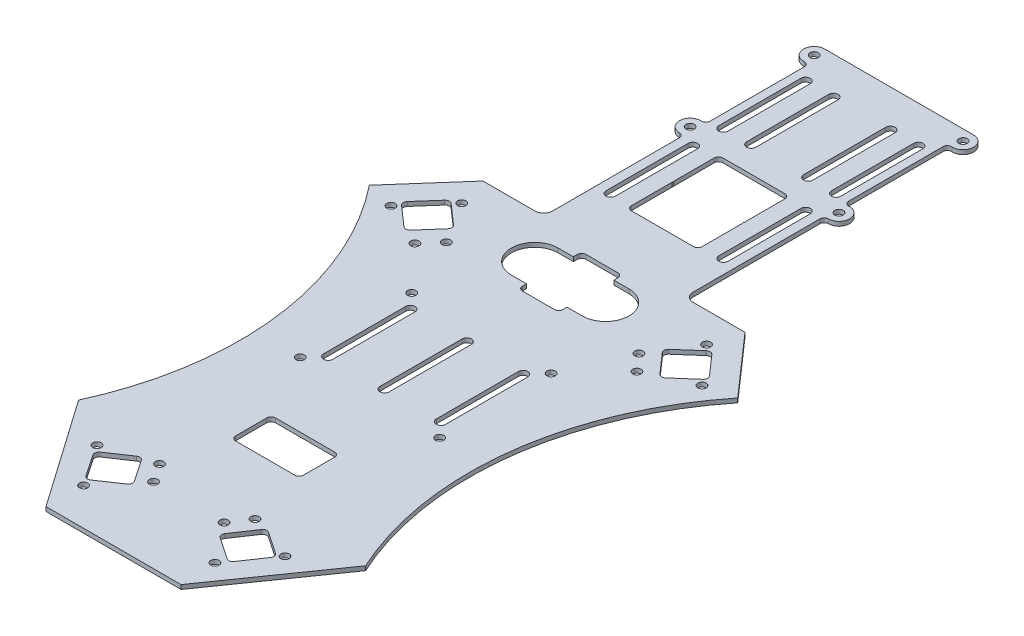
from build123d import *

# Parameters (mm, degrees)
BOSS_EXTRUDE1_DEPTH = 1.53
SKETCH2_R           = 1.5
CUT_EXTRUDE1_DEPTH  = 1.53


with BuildPart() as part:
    # Sketch1 → Boss-Extrude1 (new body)
    with BuildSketch(Plane(origin=(0, 0, 0), x_dir=(1, 0, 0), z_dir=(0, 1, 0))):
        with BuildLine():
            Line((-24.225, -100.313959073), (24.225, -100.313959073))
            Line((24.225, -100.313959073), (51.475, -61.381343132))
            ThreePointArc((51.475, -61.381343132), (41.92219647, 0.128398889), (66.075, 57.498656868))
            Line((66.075, 57.498656868), (47, 79.196040927))
            Line((47, 79.196040927), (28.38, 79.196040927))
            ThreePointArc((28.38, 79.196040927), (26.131400436, 80.127441362), (25.2, 82.376040927))
            Line((25.2, 82.376040927), (25.2, 127.896040927))
            ThreePointArc((25.2, 127.896040927), (25.639339828, 128.956701098), (26.7, 129.396040927))
            ThreePointArc((26.7, 129.396040927), (30.497925704, 133.321581153), (26.449056604, 136.987746006))
            ThreePointArc((26.449056604, 136.987746006), (25.324959734, 137.389349578), (24.85, 138.484471696))
            Line((24.85, 138.484471696), (24.85, 172.407610157))
            ThreePointArc((24.85, 172.407610157), (25.324959734, 173.502732275), (26.449056604, 173.904335847))
            ThreePointArc((26.449056604, 173.904335847), (30.497925704, 177.5705007), (26.7, 181.496040927))
            Line((26.7, 181.496040927), (-26.7, 181.496040927))
            ThreePointArc((-26.7, 181.496040927), (-30.497925704, 177.5705007), (-26.449056604, 173.904335847))
            ThreePointArc((-26.449056604, 173.904335847), (-25.324959734, 173.502732275), (-24.85, 172.407610157))
            Line((-24.85, 172.407610157), (-24.85, 138.484471696))
            ThreePointArc((-24.85, 138.484471696), (-25.324959734, 137.389349578), (-26.449056604, 136.987746006))
            ThreePointArc((-26.449056604, 136.987746006), (-30.497925704, 133.321581153), (-26.7, 129.396040927))
            ThreePointArc((-26.7, 129.396040927), (-25.639339828, 128.956701098), (-25.2, 127.896040927))
            Line((-25.2, 127.896040927), (-25.2, 82.376040927))
            ThreePointArc((-25.2, 82.376040927), (-26.131400436, 80.127441362), (-28.38, 79.196040927))
            Line((-28.38, 79.196040927), (-47, 79.196040927))
            Line((-47, 79.196040927), (-66.075, 57.498656868))
            ThreePointArc((-66.075, 57.498656868), (-41.92219647, 0.128398889), (-51.475, -61.381343132))
            Line((-51.475, -61.381343132), (-24.225, -100.313959073))
        make_face()
        with BuildLine():
            Line((-26.611630339, -83.593554115), (-31.856126021, -75.840821368))
            ThreePointArc((-31.856126021, -75.840821368), (-32.097277956, -74.663642225), (-31.43540677, -73.660730702))
            Line((-31.43540677, -73.660730702), (-23.682674023, -68.41623502))
            ThreePointArc((-23.682674023, -68.41623502), (-22.50549488, -68.175083085), (-21.502583357, -68.836954272))
            Line((-21.502583357, -68.836954272), (-16.258087675, -76.589687018))
            ThreePointArc((-16.258087675, -76.589687018), (-16.016935741, -77.766866161), (-16.678806927, -78.769777684))
            Line((-16.678806927, -78.769777684), (-24.431539674, -84.014273366))
            ThreePointArc((-24.431539674, -84.014273366), (-25.608718816, -84.255425301), (-26.611630339, -83.593554115))
        make_face(mode=Mode.SUBTRACT)
        with BuildLine():
            ThreePointArc((-21.9, 26.376040927), (-20.22, 28.056040927), (-18.54, 26.376040927))
            Line((-18.54, 26.376040927), (-18.54, -3.083959073))
            ThreePointArc((-18.54, -3.083959073), (-20.22, -4.763959073), (-21.9, -3.083959073))
            Line((-21.9, -3.083959073), (-21.9, 26.376040927))
        make_face(mode=Mode.SUBTRACT)
        with BuildLine():
            ThreePointArc((26.611630339, -83.593554115), (25.608718816, -84.255425301), (24.431539674, -84.014273366))
            Line((24.431539674, -84.014273366), (16.678806927, -78.769777684))
            ThreePointArc((16.678806927, -78.769777684), (16.016935741, -77.766866161), (16.258087675, -76.589687018))
            Line((16.258087675, -76.589687018), (21.502583357, -68.836954272))
            ThreePointArc((21.502583357, -68.836954272), (22.50549488, -68.175083085), (23.682674023, -68.41623502))
            Line((23.682674023, -68.41623502), (31.43540677, -73.660730702))
            ThreePointArc((31.43540677, -73.660730702), (32.097277956, -74.663642225), (31.856126021, -75.840821368))
            Line((31.856126021, -75.840821368), (26.611630339, -83.593554115))
        make_face(mode=Mode.SUBTRACT)
        with BuildLine():
            Line((-10.615, -31.603959073), (10.615, -31.603959073))
            ThreePointArc((10.615, -31.603959073), (11.725157646, -32.063801427), (12.185, -33.173959073))
            Line((12.185, -33.173959073), (12.185, -44.353959073))
            ThreePointArc((12.185, -44.353959073), (11.725157646, -45.46411672), (10.615, -45.923959073))
            Line((10.615, -45.923959073), (-10.615, -45.923959073))
            ThreePointArc((-10.615, -45.923959073), (-11.725157646, -45.46411672), (-12.185, -44.353959073))
            Line((-12.185, -44.353959073), (-12.185, -33.173959073))
            ThreePointArc((-12.185, -33.173959073), (-11.725157646, -32.063801427), (-10.615, -31.603959073))
        make_face(mode=Mode.SUBTRACT)
        with BuildLine():
            ThreePointArc((-1.68, 26.376040927), (0, 28.056040927), (1.68, 26.376040927))
            Line((1.68, 26.376040927), (1.68, -3.083959073))
            ThreePointArc((1.68, -3.083959073), (0, -4.763959073), (-1.68, -3.083959073))
            Line((-1.68, -3.083959073), (-1.68, 26.376040927))
        make_face(mode=Mode.SUBTRACT)
        with BuildLine():
            Line((18.54, -3.083959073), (18.54, 26.376040927))
            ThreePointArc((18.54, 26.376040927), (20.22, 28.056040927), (21.9, 26.376040927))
            Line((21.9, 26.376040927), (21.9, -3.083959073))
            ThreePointArc((21.9, -3.083959073), (20.22, -4.763959073), (18.54, -3.083959073))
        make_face(mode=Mode.SUBTRACT)
        with BuildLine():
            ThreePointArc((-54.040190621, 57.042105422), (-54.570340289, 58.120458945), (-54.182701627, 59.257842459))
            Line((-54.182701627, 59.257842459), (-47.936613015, 66.362627962))
            ThreePointArc((-47.936613015, 66.362627962), (-46.858259493, 66.892777631), (-45.720875979, 66.505138968))
            Line((-45.720875979, 66.505138968), (-38.616090475, 60.259050356))
            ThreePointArc((-38.616090475, 60.259050356), (-38.085940807, 59.180696834), (-38.473579469, 58.04331332))
            Line((-38.473579469, 58.04331332), (-44.719668081, 50.938527817))
            ThreePointArc((-44.719668081, 50.938527817), (-45.798021603, 50.408378148), (-46.935405117, 50.796016811))
            Line((-46.935405117, 50.796016811), (-54.040190621, 57.042105422))
        make_face(mode=Mode.SUBTRACT)
        with BuildLine():
            ThreePointArc((-21.9, 127.716040927), (-20.22, 129.396040927), (-18.54, 127.716040927))
            Line((-18.54, 127.716040927), (-18.54, 98.256040927))
            ThreePointArc((-18.54, 98.256040927), (-20.22, 96.576040927), (-21.9, 98.256040927))
            Line((-21.9, 98.256040927), (-21.9, 127.716040927))
        make_face(mode=Mode.SUBTRACT)
        with BuildLine():
            ThreePointArc((-21.9, 168.127746006), (-20.22, 169.807746006), (-18.54, 168.127746006))
            Line((-18.54, 168.127746006), (-18.54, 138.667746006))
            ThreePointArc((-18.54, 138.667746006), (-20.22, 136.987746006), (-21.9, 138.667746006))
            Line((-21.9, 138.667746006), (-21.9, 168.127746006))
        make_face(mode=Mode.SUBTRACT)
        with BuildLine():
            ThreePointArc((-11.9, 168.127746006), (-10.22, 169.807746006), (-8.54, 168.127746006))
            Line((-8.54, 168.127746006), (-8.54, 138.667746006))
            ThreePointArc((-8.54, 138.667746006), (-10.22, 136.987746006), (-11.9, 138.667746006))
            Line((-11.9, 138.667746006), (-11.9, 168.127746006))
        make_face(mode=Mode.SUBTRACT)
        with BuildLine():
            ThreePointArc((-12.7, 55.076040927), (-21.1, 63.476040927), (-12.7, 71.876040927))
            Line((-12.7, 71.876040927), (-7.265, 71.876040927))
            Line((-7.265, 71.876040927), (-7.265, 73.306040927))
            ThreePointArc((-7.265, 73.306040927), (-6.805157646, 74.416198573), (-5.695, 74.876040927))
            Line((-5.695, 74.876040927), (5.695, 74.876040927))
            ThreePointArc((5.695, 74.876040927), (6.805157646, 74.416198573), (7.265, 73.306040927))
            Line((7.265, 73.306040927), (7.265, 71.876040927))
            Line((7.265, 71.876040927), (12.7, 71.876040927))
            ThreePointArc((12.7, 71.876040927), (21.1, 63.476040927), (12.7, 55.076040927))
            Line((12.7, 55.076040927), (7.265, 55.076040927))
            Line((7.265, 55.076040927), (7.265, 53.646040927))
            ThreePointArc((7.265, 53.646040927), (6.805157646, 52.53588328), (5.695, 52.076040927))
            Line((5.695, 52.076040927), (-5.695, 52.076040927))
            ThreePointArc((-5.695, 52.076040927), (-6.805157646, 52.53588328), (-7.265, 53.646040927))
            Line((-7.265, 53.646040927), (-7.265, 55.076040927))
            Line((-7.265, 55.076040927), (-12.7, 55.076040927))
        make_face(mode=Mode.SUBTRACT)
        with BuildLine():
            ThreePointArc((54.182701627, 59.257842459), (54.570340289, 58.120458945), (54.040190621, 57.042105422))
            Line((54.040190621, 57.042105422), (46.935405117, 50.796016811))
            ThreePointArc((46.935405117, 50.796016811), (45.798021603, 50.408378148), (44.719668081, 50.938527817))
            Line((44.719668081, 50.938527817), (38.473579469, 58.04331332))
            ThreePointArc((38.473579469, 58.04331332), (38.085940807, 59.180696834), (38.616090475, 60.259050356))
            Line((38.616090475, 60.259050356), (45.720875979, 66.505138968))
            ThreePointArc((45.720875979, 66.505138968), (46.858259493, 66.892777631), (47.936613015, 66.362627962))
            Line((47.936613015, 66.362627962), (54.182701627, 59.257842459))
        make_face(mode=Mode.SUBTRACT)
        with BuildLine():
            Line((-11.13, 129.396040927), (11.13, 129.396040927))
            ThreePointArc((11.13, 129.396040927), (12.240157646, 128.936198573), (12.7, 127.826040927))
            Line((12.7, 127.826040927), (12.7, 113.506040927))
            ThreePointArc((12.7, 113.506040927), (12.677687573, 113.242292605), (12.611384488, 112.986040927))
            ThreePointArc((12.611384488, 112.986040927), (12.677687573, 112.729789248), (12.7, 112.466040927))
            Line((12.7, 112.466040927), (12.7, 98.146040927))
            ThreePointArc((12.7, 98.146040927), (12.240157646, 97.03588328), (11.13, 96.576040927))
            Line((11.13, 96.576040927), (-11.13, 96.576040927))
            ThreePointArc((-11.13, 96.576040927), (-12.240157646, 97.03588328), (-12.7, 98.146040927))
            Line((-12.7, 98.146040927), (-12.7, 112.466040927))
            ThreePointArc((-12.7, 112.466040927), (-12.677687573, 112.729789248), (-12.611384488, 112.986040927))
            ThreePointArc((-12.611384488, 112.986040927), (-12.677687573, 113.242292605), (-12.7, 113.506040927))
            Line((-12.7, 113.506040927), (-12.7, 127.826040927))
            ThreePointArc((-12.7, 127.826040927), (-12.240157646, 128.936198573), (-11.13, 129.396040927))
        make_face(mode=Mode.SUBTRACT)
        with BuildLine():
            Line((18.54, 98.256040927), (18.54, 127.716040927))
            ThreePointArc((18.54, 127.716040927), (20.22, 129.396040927), (21.9, 127.716040927))
            Line((21.9, 127.716040927), (21.9, 98.256040927))
            ThreePointArc((21.9, 98.256040927), (20.22, 96.576040927), (18.54, 98.256040927))
        make_face(mode=Mode.SUBTRACT)
        with BuildLine():
            Line((8.54, 138.667746006), (8.54, 168.127746006))
            ThreePointArc((8.54, 168.127746006), (10.22, 169.807746006), (11.9, 168.127746006))
            Line((11.9, 168.127746006), (11.9, 138.667746006))
            ThreePointArc((11.9, 138.667746006), (10.22, 136.987746006), (8.54, 138.667746006))
        make_face(mode=Mode.SUBTRACT)
        with BuildLine():
            Line((18.54, 138.667746006), (18.54, 168.127746006))
            ThreePointArc((18.54, 168.127746006), (20.22, 169.807746006), (21.9, 168.127746006))
            Line((21.9, 168.127746006), (21.9, 138.667746006))
            ThreePointArc((21.9, 138.667746006), (20.22, 136.987746006), (18.54, 138.667746006))
        make_face(mode=Mode.SUBTRACT)
    extrude(amount=BOSS_EXTRUDE1_DEPTH)

    # Sketch2 → Cut-Extrude1 (cut)
    with BuildSketch(Plane(origin=(0, 1.53, 0), x_dir=(1, 0, 0), z_dir=(0, 1, 0))):
        with Locations((-26.7, 177.696040927)):
            Circle(SKETCH2_R)
        with Locations((26.7, 177.696040927)):
            Circle(SKETCH2_R)
        with Locations((-26.7, 133.196040927)):
            Circle(SKETCH2_R)
        with Locations((26.7, 133.196040927)):
            Circle(SKETCH2_R)
        with Locations((-39.820364027, 47.603355031)):
            Circle(SKETCH2_R)
        with Locations((-34.538259493, 53.611630299)):
            Circle(SKETCH2_R)
        with Locations((-55.784735202, 54.980759595)):
            Circle(SKETCH2_R)
        with Locations((-43.9, 68.499378946)):
            Circle(SKETCH2_R)
        with Locations((-25.005, 31.646040927)):
            Circle(SKETCH2_R)
        with Locations((-25.005, -8.353959073)):
            Circle(SKETCH2_R)
        with Locations((-17.123700323, -66.695743719)):
            Circle(SKETCH2_R)
        with Locations((-12.641225381, -73.322011024)):
            Circle(SKETCH2_R)
        with Locations((-34.146794, -72.088624164)):
            Circle(SKETCH2_R)
        with Locations((-24.061225381, -86.9977256)):
            Circle(SKETCH2_R)
        with Locations((34.091460041, -72.889396604)):
            Circle(SKETCH2_R)
        with Locations((23.536438938, -87.46991544)):
            Circle(SKETCH2_R)
        with Locations((12.641225381, -73.322011024)):
            Circle(SKETCH2_R)
        with Locations((17.123700323, -66.695743719)):
            Circle(SKETCH2_R)
        with Locations((25.005, -8.353959073)):
            Circle(SKETCH2_R)
        with Locations((25.005, 31.646040927)):
            Circle(SKETCH2_R)
        with Locations((39.820364027, 47.603355031)):
            Circle(SKETCH2_R)
        with Locations((34.538259493, 53.611630299)):
            Circle(SKETCH2_R)
        with Locations((55.784735202, 54.980759595)):
            Circle(SKETCH2_R)
        with Locations((43.9, 68.499378946)):
            Circle(SKETCH2_R)
    extrude(amount=-CUT_EXTRUDE1_DEPTH, mode=Mode.SUBTRACT)


solid = part.part
